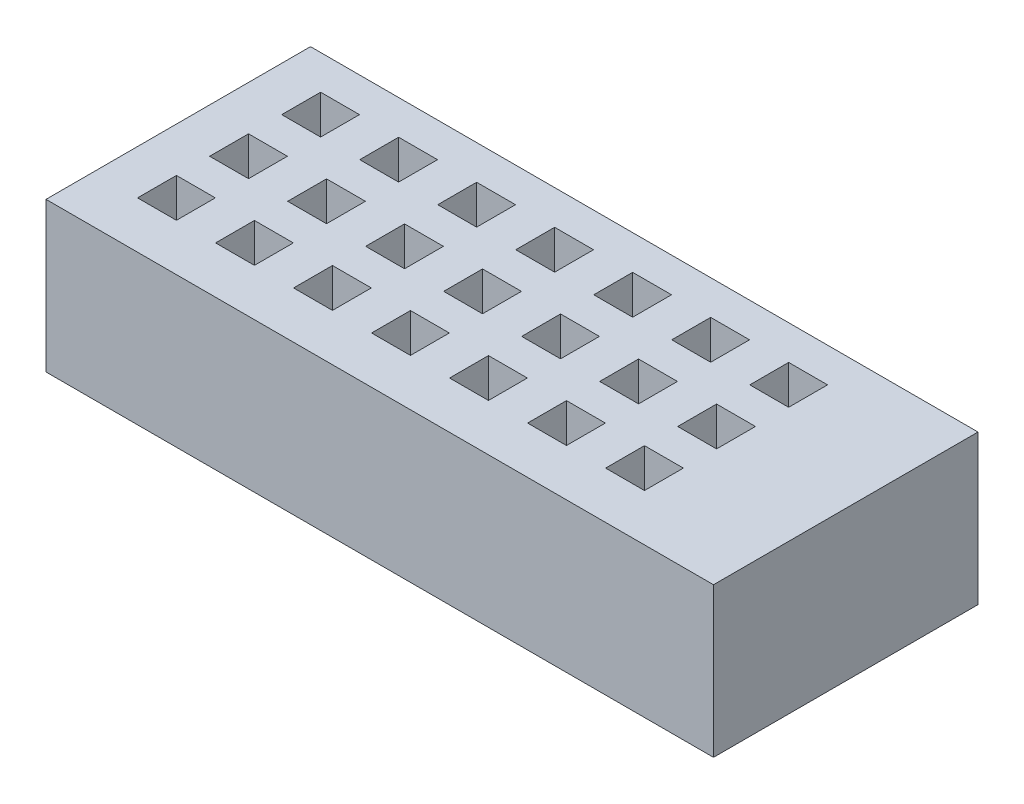
from build123d import *

# Parameters (mm, degrees)
SKETCH2_W           = 47.625
SKETCH2_H           = 18.8722
SKETCH2_W_2         = 3.683
SKETCH2_H_2         = 1.0922
BOSS_EXTRUDE2_DEPTH = 6.858
SKETCH4_R           = 0.731
CUT_EXTRUDE1_DEPTH  = 7.858
SKETCH5_W           = 47.625
SKETCH5_H           = 18.8722
SKETCH5_W_2         = 2.774
SKETCH5_H_2         = 2.774
BOSS_EXTRUDE3_DEPTH = 3.81
SKETCH6_W           = 4.812835231
SKETCH6_H           = 18.8722
BOSS_EXTRUDE4_DEPTH = 3.81


with BuildPart() as part:
    # Sketch2 → Boss-Extrude2 (new body)
    with BuildSketch(Plane.XZ.offset(-8.128)):
        with Locations((20.5105, -5.3721)):
            Rectangle(SKETCH2_W, SKETCH2_H)
        with Locations((1.5875, -0.2921)):
            Rectangle(SKETCH2_W_2, SKETCH2_H_2, mode=Mode.SUBTRACT)
        with Locations((7.102928571, -0.2921)):
            Rectangle(SKETCH2_W_2, SKETCH2_H_2, mode=Mode.SUBTRACT)
        with Locations((12.618357143, -0.2921)):
            Rectangle(SKETCH2_W_2, SKETCH2_H_2, mode=Mode.SUBTRACT)
        with Locations((18.133785714, -0.2921)):
            Rectangle(SKETCH2_W_2, SKETCH2_H_2, mode=Mode.SUBTRACT)
        with Locations((23.649214286, -0.2921)):
            Rectangle(SKETCH2_W_2, SKETCH2_H_2, mode=Mode.SUBTRACT)
        with Locations((29.164642857, -0.2921)):
            Rectangle(SKETCH2_W_2, SKETCH2_H_2, mode=Mode.SUBTRACT)
        with Locations((34.680071429, -0.2921)):
            Rectangle(SKETCH2_W_2, SKETCH2_H_2, mode=Mode.SUBTRACT)
        with Locations((40.1955, -0.2921)):
            Rectangle(SKETCH2_W_2, SKETCH2_H_2, mode=Mode.SUBTRACT)
        with Locations((7.102928571, -5.3721)):
            Rectangle(SKETCH2_W_2, SKETCH2_H_2, mode=Mode.SUBTRACT)
        with Locations((12.618357143, -5.3721)):
            Rectangle(SKETCH2_W_2, SKETCH2_H_2, mode=Mode.SUBTRACT)
        with Locations((18.133785714, -5.3721)):
            Rectangle(SKETCH2_W_2, SKETCH2_H_2, mode=Mode.SUBTRACT)
        with Locations((23.649214286, -5.3721)):
            Rectangle(SKETCH2_W_2, SKETCH2_H_2, mode=Mode.SUBTRACT)
        with Locations((29.164642857, -5.3721)):
            Rectangle(SKETCH2_W_2, SKETCH2_H_2, mode=Mode.SUBTRACT)
        with Locations((34.680071429, -5.3721)):
            Rectangle(SKETCH2_W_2, SKETCH2_H_2, mode=Mode.SUBTRACT)
        with Locations((40.1955, -5.3721)):
            Rectangle(SKETCH2_W_2, SKETCH2_H_2, mode=Mode.SUBTRACT)
        with Locations((7.102928571, -10.4521)):
            Rectangle(SKETCH2_W_2, SKETCH2_H_2, mode=Mode.SUBTRACT)
        with Locations((12.618357143, -10.4521)):
            Rectangle(SKETCH2_W_2, SKETCH2_H_2, mode=Mode.SUBTRACT)
        with Locations((18.133785714, -10.4521)):
            Rectangle(SKETCH2_W_2, SKETCH2_H_2, mode=Mode.SUBTRACT)
        with Locations((23.649214286, -10.4521)):
            Rectangle(SKETCH2_W_2, SKETCH2_H_2, mode=Mode.SUBTRACT)
        with Locations((29.164642857, -10.4521)):
            Rectangle(SKETCH2_W_2, SKETCH2_H_2, mode=Mode.SUBTRACT)
        with Locations((34.680071429, -10.4521)):
            Rectangle(SKETCH2_W_2, SKETCH2_H_2, mode=Mode.SUBTRACT)
        with Locations((40.1955, -10.4521)):
            Rectangle(SKETCH2_W_2, SKETCH2_H_2, mode=Mode.SUBTRACT)
        with Locations((1.5875, -5.3721)):
            Rectangle(SKETCH2_W_2, SKETCH2_H_2, mode=Mode.SUBTRACT)
        with Locations((1.5875, -10.4521)):
            Rectangle(SKETCH2_W_2, SKETCH2_H_2, mode=Mode.SUBTRACT)
    extrude(amount=BOSS_EXTRUDE2_DEPTH)

    # Sketch4 → Cut-Extrude1 (cut, through all)
    with BuildSketch(Plane(origin=(0, 8.128, 0), x_dir=(1, 0, 0), z_dir=(0, 1, 0))):
        with Locations((1.26, 0.6802)):
            Circle(SKETCH4_R)
        with Locations((6.825769444, 0.6802)):
            Circle(SKETCH4_R)
        with Locations((12.391538887, 0.6802)):
            Circle(SKETCH4_R)
        with Locations((17.957308331, 0.6802)):
            Circle(SKETCH4_R)
        with Locations((23.523077775, 0.6802)):
            Circle(SKETCH4_R)
        with Locations((29.088847219, 0.6802)):
            Circle(SKETCH4_R)
        with Locations((34.654616662, 0.6802)):
            Circle(SKETCH4_R)
        with Locations((40.220386106, 0.6802)):
            Circle(SKETCH4_R)
        with Locations((6.825769444, 5.7602)):
            Circle(SKETCH4_R)
        with Locations((12.391538887, 5.7602)):
            Circle(SKETCH4_R)
        with Locations((17.957308331, 5.7602)):
            Circle(SKETCH4_R)
        with Locations((23.523077775, 5.7602)):
            Circle(SKETCH4_R)
        with Locations((29.088847219, 5.7602)):
            Circle(SKETCH4_R)
        with Locations((34.654616662, 5.7602)):
            Circle(SKETCH4_R)
        with Locations((40.220386106, 5.7602)):
            Circle(SKETCH4_R)
        with Locations((1.26, 5.7602)):
            Circle(SKETCH4_R)
        with Locations((1.26, 10.8402)):
            Circle(SKETCH4_R)
        with Locations((6.825769444, 10.8402)):
            Circle(SKETCH4_R)
        with Locations((12.391538887, 10.8402)):
            Circle(SKETCH4_R)
        with Locations((17.957308331, 10.8402)):
            Circle(SKETCH4_R)
        with Locations((23.523077775, 10.8402)):
            Circle(SKETCH4_R)
        with Locations((29.088847219, 10.8402)):
            Circle(SKETCH4_R)
        with Locations((34.654616662, 10.8402)):
            Circle(SKETCH4_R)
        with Locations((40.220386106, 10.8402)):
            Circle(SKETCH4_R)
    extrude(amount=-CUT_EXTRUDE1_DEPTH, mode=Mode.SUBTRACT)

    # Sketch5 → Boss-Extrude3 (add)
    with BuildSketch(Plane(origin=(0, 8.128, 0), x_dir=(1, 0, 0), z_dir=(0, 1, 0))):
        with Locations((20.5105, 5.3721)):
            Rectangle(SKETCH5_W, SKETCH5_H)
        with Locations((6.825769444, 0.6802)):
            Rectangle(SKETCH5_W_2, SKETCH5_H_2, mode=Mode.SUBTRACT)
        with Locations((12.391538887, 0.6802)):
            Rectangle(SKETCH5_W_2, SKETCH5_H_2, mode=Mode.SUBTRACT)
        with Locations((1.26, 0.6802)):
            Rectangle(SKETCH5_W_2, SKETCH5_H_2, mode=Mode.SUBTRACT)
        with Locations((17.957308331, 0.6802)):
            Rectangle(SKETCH5_W_2, SKETCH5_H_2, mode=Mode.SUBTRACT)
        with Locations((23.523077775, 0.6802)):
            Rectangle(SKETCH5_W_2, SKETCH5_H_2, mode=Mode.SUBTRACT)
        with Locations((29.088847219, 0.6802)):
            Rectangle(SKETCH5_W_2, SKETCH5_H_2, mode=Mode.SUBTRACT)
        with Locations((34.654616662, 0.6802)):
            Rectangle(SKETCH5_W_2, SKETCH5_H_2, mode=Mode.SUBTRACT)
        with Locations((40.220386106, 0.6802)):
            Rectangle(SKETCH5_W_2, SKETCH5_H_2, mode=Mode.SUBTRACT)
        with Locations((6.825769444, 5.8237)):
            Rectangle(SKETCH5_W_2, SKETCH5_H_2, mode=Mode.SUBTRACT)
        with Locations((12.391538887, 5.8237)):
            Rectangle(SKETCH5_W_2, SKETCH5_H_2, mode=Mode.SUBTRACT)
        with Locations((17.957308331, 5.8237)):
            Rectangle(SKETCH5_W_2, SKETCH5_H_2, mode=Mode.SUBTRACT)
        with Locations((23.523077775, 5.8237)):
            Rectangle(SKETCH5_W_2, SKETCH5_H_2, mode=Mode.SUBTRACT)
        with Locations((29.088847219, 5.8237)):
            Rectangle(SKETCH5_W_2, SKETCH5_H_2, mode=Mode.SUBTRACT)
        with Locations((34.654616662, 5.8237)):
            Rectangle(SKETCH5_W_2, SKETCH5_H_2, mode=Mode.SUBTRACT)
        with Locations((40.220386106, 5.8237)):
            Rectangle(SKETCH5_W_2, SKETCH5_H_2, mode=Mode.SUBTRACT)
        with Locations((1.26, 5.8237)):
            Rectangle(SKETCH5_W_2, SKETCH5_H_2, mode=Mode.SUBTRACT)
        with Locations((1.26, 10.9672)):
            Rectangle(SKETCH5_W_2, SKETCH5_H_2, mode=Mode.SUBTRACT)
        with Locations((6.825769444, 10.9672)):
            Rectangle(SKETCH5_W_2, SKETCH5_H_2, mode=Mode.SUBTRACT)
        with Locations((12.391538887, 10.9672)):
            Rectangle(SKETCH5_W_2, SKETCH5_H_2, mode=Mode.SUBTRACT)
        with Locations((17.957308331, 10.9672)):
            Rectangle(SKETCH5_W_2, SKETCH5_H_2, mode=Mode.SUBTRACT)
        with Locations((23.523077775, 10.9672)):
            Rectangle(SKETCH5_W_2, SKETCH5_H_2, mode=Mode.SUBTRACT)
        with Locations((29.088847219, 10.9672)):
            Rectangle(SKETCH5_W_2, SKETCH5_H_2, mode=Mode.SUBTRACT)
        with Locations((34.654616662, 10.9672)):
            Rectangle(SKETCH5_W_2, SKETCH5_H_2, mode=Mode.SUBTRACT)
        with Locations((40.220386106, 10.9672)):
            Rectangle(SKETCH5_W_2, SKETCH5_H_2, mode=Mode.SUBTRACT)
    extrude(amount=BOSS_EXTRUDE3_DEPTH)

    # Sketch6 → Boss-Extrude4 (add)
    with BuildSketch(Plane(origin=(0, 8.128, 0), x_dir=(1, 0, 0), z_dir=(0, 1, 0))):
        with Locations((40.494340128, 5.3721)):
            Rectangle(SKETCH6_W, SKETCH6_H)
    extrude(amount=BOSS_EXTRUDE4_DEPTH)


solid = part.part
